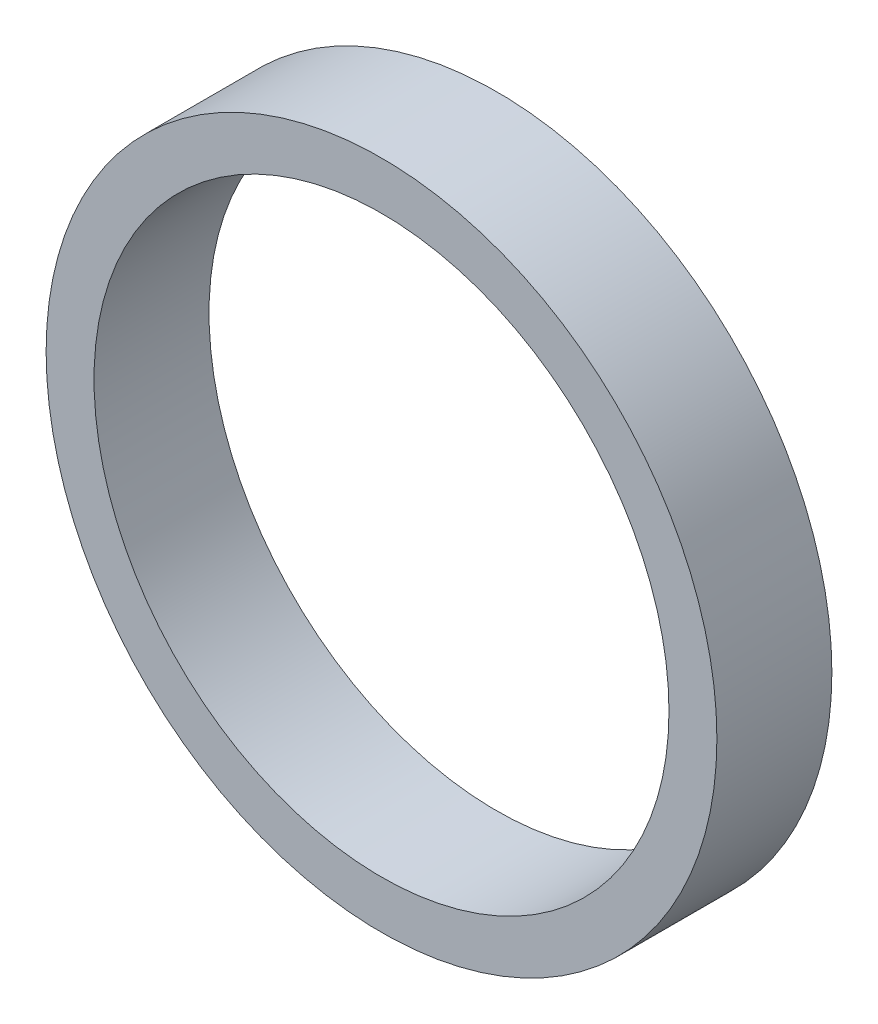
from build123d import *

# Parameters (mm, degrees)
CROQUIS1_R              = 17.5
CROQUIS1_R_2            = 15
SALIENTE_EXTRUIR1_DEPTH = 6


with BuildPart() as part:
    # Croquis1 → Saliente-Extruir1 (new body)
    with BuildSketch(Plane.XY):
        Circle(CROQUIS1_R)
        Circle(CROQUIS1_R_2, mode=Mode.SUBTRACT)
    extrude(amount=SALIENTE_EXTRUIR1_DEPTH)


solid = part.part
